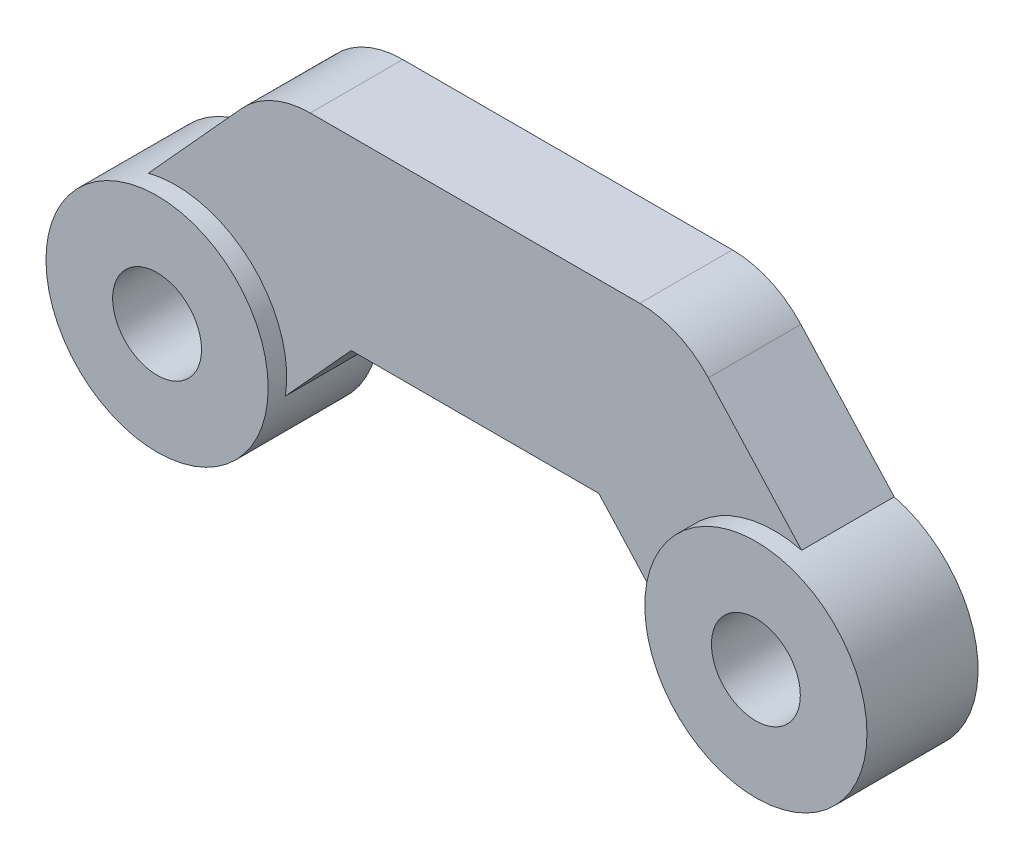
from build123d import *

# Parameters (mm, degrees)
SKETCH1_R                = 1.2
BOSS_EXTRUDE1_DEPTH      = 1.25
SKETCH2_R                = 3
SKETCH2_R_2              = 1.2
BOSS_EXTRUDE2_DEPTH      = 0.5
BOSS_EXTRUDE2_DEPTH_BACK = 2.5


with BuildPart() as part:
    # Sketch1 → Boss-Extrude1 (new body, symmetric)
    with BuildSketch(Plane.XY):
        with BuildLine():
            Line((-6.234807428, -1.68130528), (-3.34389464, 1.5))
            Line((-3.34389464, 1.5), (3.34389464, 1.5))
            Line((3.34389464, 1.5), (6.234807428, -1.68130528))
            ThreePointArc((6.234807428, -1.68130528), (9.76630528, -1.850192572), (9.935192572, 1.68130528))
            Line((9.935192572, 1.68130528), (6.300316278, 5.68130528))
            ThreePointArc((6.300316278, 5.68130528), (5.461740431, 6.286182757), (4.450123705, 6.5))
            Line((4.450123705, 6.5), (-4.450123705, 6.5))
            ThreePointArc((-4.450123705, 6.5), (-5.461740431, 6.286182757), (-6.300316278, 5.68130528))
            Line((-6.300316278, 5.68130528), (-9.935192572, 1.68130528))
            ThreePointArc((-9.935192572, 1.68130528), (-9.76630528, -1.850192572), (-6.234807428, -1.68130528))
        make_face()
        with Locations((-8.085, 0)):
            Circle(SKETCH1_R, mode=Mode.SUBTRACT)
        with Locations((8.085, 0)):
            Circle(SKETCH1_R, mode=Mode.SUBTRACT)
    extrude(amount=BOSS_EXTRUDE1_DEPTH, both=True)

    # Sketch2 → Boss-Extrude2 (add, two sides)
    with BuildSketch(Plane.XY.offset(1.25)) as boss_extrude2_sk:
        with Locations((8.085, 0)):
            Circle(SKETCH2_R)
        with Locations((8.085, 0)):
            Circle(SKETCH2_R_2, mode=Mode.SUBTRACT)
        with Locations((-8.085, 0)):
            Circle(SKETCH2_R)
        with Locations((-8.085, 0)):
            Circle(SKETCH2_R_2, mode=Mode.SUBTRACT)
    extrude(amount=BOSS_EXTRUDE2_DEPTH)
    extrude(boss_extrude2_sk.sketch, amount=-BOSS_EXTRUDE2_DEPTH_BACK)


solid = part.part
